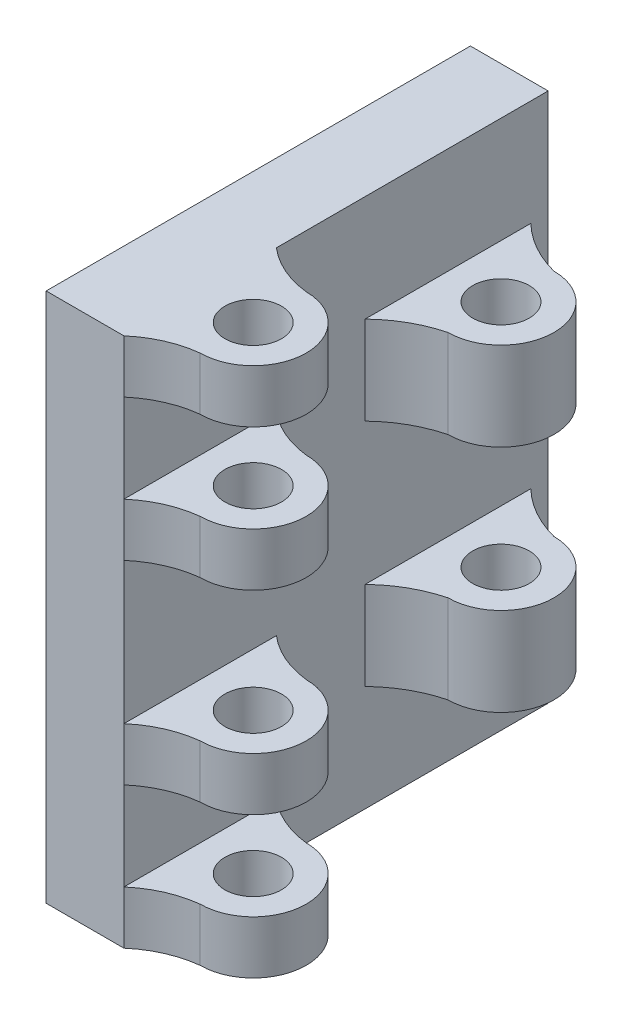
from build123d import *

# Parameters (mm, degrees)
SZKIC2_W                    = 22
SZKIC2_H                    = 120
DODANIE_WYCI_GNI_CIE1_DEPTH = 150
SZKIC3_R                    = 8
DODANIE_WYCI_GNI_CIE2_DEPTH = 15
SZYK_LINIOWY1_COUNT         = 2
SZYK_LINIOWY1_PITCH         = 40
SZYK_LINIOWY2_COUNT         = 2
SZYK_LINIOWY2_PITCH         = 135
SZYK_LINIOWY3_COUNT         = 2
SZYK_LINIOWY3_PITCH         = 95
SZKIC4_R                    = 8
DODANIE_WYCI_GNI_CIE3_DEPTH = 25
SZYK_LINIOWY4_COUNT         = 2
SZYK_LINIOWY4_PITCH         = 65


with BuildPart() as part:
    # Szkic2 → Dodanie-wyciągnięcie1 (new body)
    with BuildSketch(Plane(origin=(0, 0, 0), x_dir=(1, 0, 0), z_dir=(0, 1, 0))):
        Rectangle(SZKIC2_W, SZKIC2_H)
    extrude(amount=DODANIE_WYCI_GNI_CIE1_DEPTH)

    # Szkic3 → Dodanie-wyciągnięcie2 (add)
    with BuildSketch(Plane(origin=(0, 0, 0), x_dir=(1, 0, 0), z_dir=(0, 1, 0))):
        with BuildLine():
            Line((11, -16.864863098), (11, -60))
            ThreePointArc((11, -60), (18.004271641, -55.583996835), (26, -53.432431549))
            ThreePointArc((26, -53.432431549), (41, -38.432431549), (26, -23.432431549))
            ThreePointArc((26, -23.432431549), (18.004271641, -21.280866263), (11, -16.864863098))
        make_face()
        with Locations((26, -38.432431549)):
            Circle(SZKIC3_R, mode=Mode.SUBTRACT)
    dodanie_wyci_gni_cie2 = extrude(amount=DODANIE_WYCI_GNI_CIE2_DEPTH)

    # Szyk liniowy1: Dodanie-wyciągnięcie2 ×2
    with Locations(*[(0, i * SZYK_LINIOWY1_PITCH, 0) for i in range(1, SZYK_LINIOWY1_COUNT)]):
        add(dodanie_wyci_gni_cie2)

    # Szyk liniowy2: Dodanie-wyciągnięcie2 ×2
    with Locations(*[(0, i * SZYK_LINIOWY2_PITCH, 0) for i in range(1, SZYK_LINIOWY2_COUNT)]):
        add(dodanie_wyci_gni_cie2)

    # Szyk liniowy3: Dodanie-wyciągnięcie2 ×2
    with Locations(*[(0, i * SZYK_LINIOWY3_PITCH, 0) for i in range(1, SZYK_LINIOWY3_COUNT)]):
        add(dodanie_wyci_gni_cie2)

    # Szkic4 → Dodanie-wyciągnięcie3 (add)
    with BuildSketch(Plane(origin=(0, 30, 0), x_dir=(-1, 0, 0), z_dir=(0, -1, 0))):
        with BuildLine():
            Line((-11, 55.095776214), (-11, 8.216275777))
            ThreePointArc((-11, 8.216275777), (-17.948621334, 13.416118275), (-26, 16.656025995))
            ThreePointArc((-26, 16.656025995), (-41, 31.656025995), (-26, 46.656025995))
            ThreePointArc((-26, 46.656025995), (-17.948621334, 49.895933715), (-11, 55.095776214))
        make_face()
        with Locations((-26, 31.656025995)):
            Circle(SZKIC4_R, mode=Mode.SUBTRACT)
    dodanie_wyci_gni_cie3 = extrude(amount=-DODANIE_WYCI_GNI_CIE3_DEPTH)

    # Szyk liniowy4: Dodanie-wyciągnięcie3 ×2
    with Locations(*[(0, i * SZYK_LINIOWY4_PITCH, 0) for i in range(1, SZYK_LINIOWY4_COUNT)]):
        add(dodanie_wyci_gni_cie3)


solid = part.part
